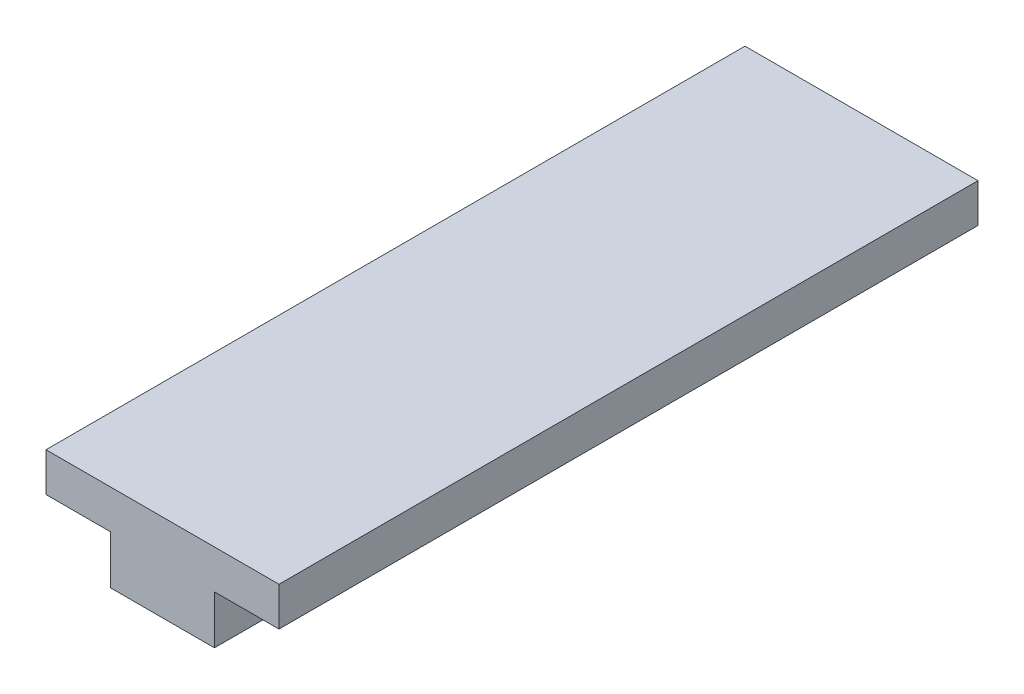
from build123d import *

# Parameters (mm, degrees)
SKETCH1_W           = 72
SKETCH1_H           = 4
BOSS_EXTRUDE1_DEPTH = 12
BOSS_EXTRUDE2_DEPTH = 5


with BuildPart() as part:
    # Sketch1 → Boss-Extrude1 (new, symmetric)
    with BuildSketch(Plane(origin=(0, 0, 0), x_dir=(0, 0, -1), z_dir=(1, 0, 0))):
        with Locations((36, 2)):
            Rectangle(SKETCH1_W, SKETCH1_H)
    extrude(amount=BOSS_EXTRUDE1_DEPTH, both=True)

    # Sketch2 → Boss-Extrude2 (add)
    with BuildSketch(Plane(origin=(0, 0, 0), x_dir=(1, 0, 0), z_dir=(0, 1, 0))):
        with BuildLine():
            Line((-5.35, 44.65), (-5.35, 0))
            Line((-5.35, 0), (5.35, 0))
            Line((5.35, 0), (5.35, 44.65))
            ThreePointArc((5.35, 44.65), (0, 50), (-5.35, 44.65))
        make_face()
    extrude(amount=-BOSS_EXTRUDE2_DEPTH)


solid = part.part
